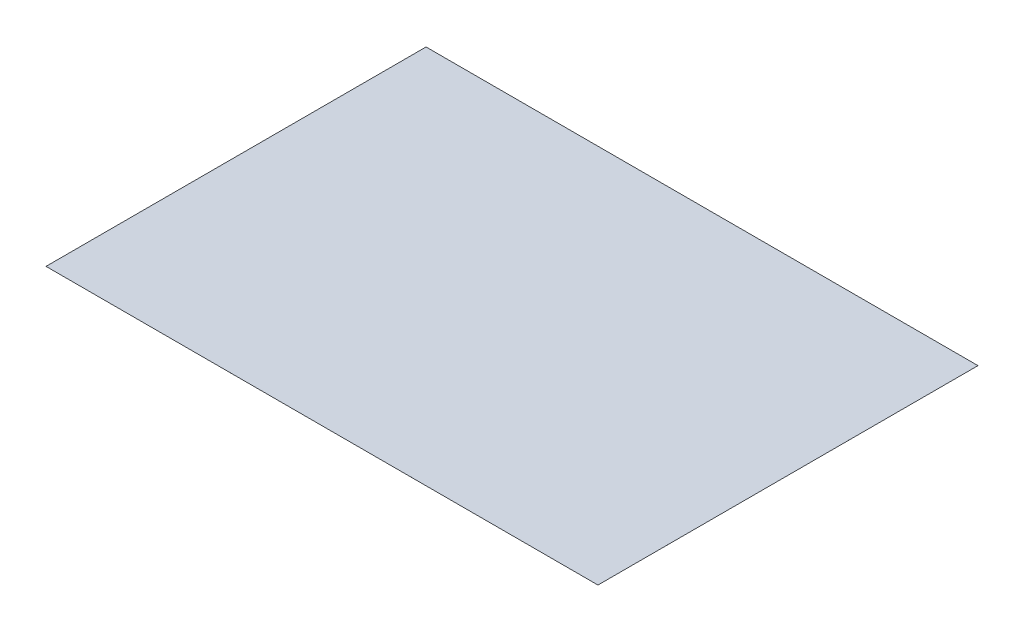
from build123d import *

# Parameters (mm, degrees)
SKETCH1_W           = 57.15
SKETCH1_H           = 39.35
BOSS_EXTRUDE1_DEPTH = 0.0001


with BuildPart() as part:
    # Sketch1 → Boss-Extrude1 (new body)
    with BuildSketch(Plane(origin=(0, 0, 0), x_dir=(1, 0, 0), z_dir=(0, 1, 0))):
        with Locations((-5.373826646, -0.385941194)):
            Rectangle(SKETCH1_W, SKETCH1_H)
    extrude(amount=BOSS_EXTRUDE1_DEPTH)


solid = part.part
